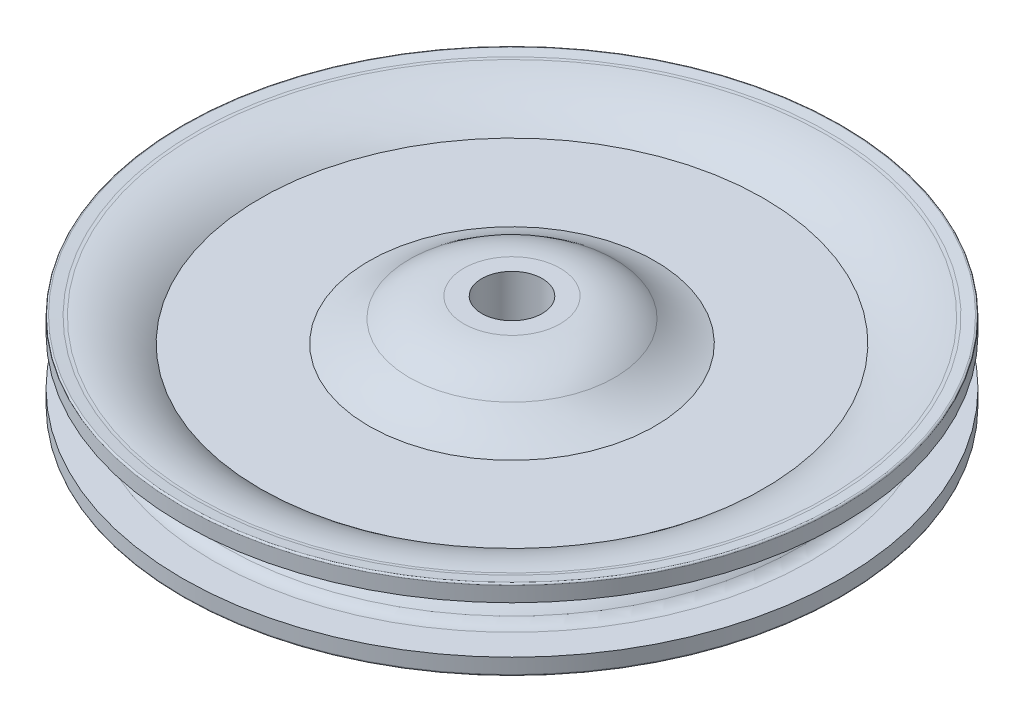
from build123d import *


with BuildPart() as part:
    # Sketch1 → Revolve1 (revolve)
    with BuildSketch(Plane.XY):
        with BuildLine():
            Line((4.95935, -9.21385), (4.95935, 9.21385))
            Line((4.95935, 9.21385), (7.89305, 9.21385))
            ThreePointArc((7.89305, 9.21385), (12.622615793, 8.395381928), (16.8021, 6.035171274))
            ThreePointArc((16.8021, 6.035171274), (19.944763719, 3.935351603), (23.4315, 2.4765))
            Line((23.4315, 2.4765), (41.2115, 2.4765))
            ThreePointArc((41.2115, 2.4765), (46.014329859, 5.310008445), (51.49318649, 6.348312243))
            ThreePointArc((51.49318649, 6.348312243), (51.743719687, 6.358115724), (51.993464036, 6.38026864))
            Line((51.993464036, 6.38026864), (53.679620939, 6.571877379))
            ThreePointArc((53.679620939, 6.571877379), (53.877461932, 6.508975233), (53.9623, 6.319501645))
            Line((53.9623, 6.319501645), (53.9623, 3.8608))
            Line((53.9623, 3.8608), (48.96567957, 3.8608))
            ThreePointArc((48.96567957, 3.8608), (47.8854091, 3.619629204), (47.010280116, 2.941914732))
            ThreePointArc((47.010280116, 2.941914732), (45.42808425, 1.328415294), (43.599960349, 0))
            ThreePointArc((43.599960349, 0), (45.42808425, -1.328415294), (47.010280116, -2.941914732))
            ThreePointArc((47.010280116, -2.941914732), (47.8854091, -3.619629204), (48.96567957, -3.8608))
            Line((48.96567957, -3.8608), (53.9623, -3.8608))
            Line((53.9623, -3.8608), (53.9623, -6.319501645))
            ThreePointArc((53.9623, -6.319501645), (53.877461932, -6.508975233), (53.679620939, -6.571877379))
            Line((53.679620939, -6.571877379), (51.7271, -6.35))
            ThreePointArc((51.7271, -6.35), (46.123934698, -5.350831869), (41.2115, -2.4765))
            Line((41.2115, -2.4765), (23.4315, -2.4765))
            ThreePointArc((23.4315, -2.4765), (19.944763719, -3.935351603), (16.8021, -6.035171274))
            ThreePointArc((16.8021, -6.035171274), (12.622615793, -8.395381928), (7.89305, -9.21385))
            Line((7.89305, -9.21385), (4.95935, -9.21385))
        make_face()
    revolve(axis=Axis((0, 28.575302381, 0), (0, -1, 0)))


solid = part.part
